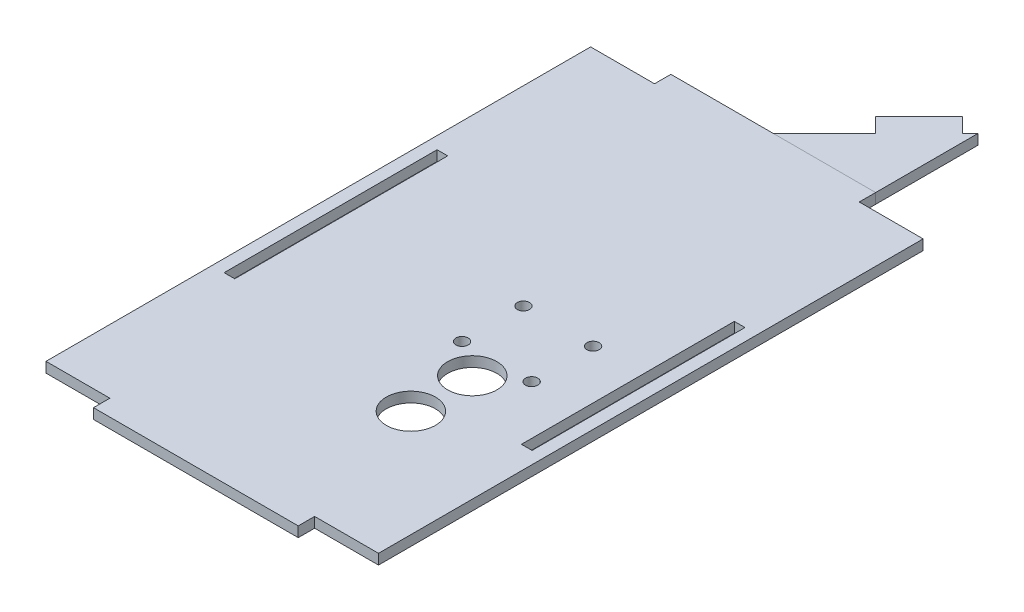
from build123d import *

# Parameters (mm, degrees)
SKETCH1_W           = 2.6
SKETCH1_H           = 52
BOSS_EXTRUDE1_DEPTH = 2.5
SKETCH2_R           = 6
CUT_EXTRUDE1_DEPTH  = 3.5
SKETCH3_R           = 1.5
CUT_EXTRUDE2_DEPTH  = 3.5
SKETCH4_R           = 6
SKETCH4_R_2         = 1.5
CUT_EXTRUDE3_DEPTH  = 3.5
BOSS_EXTRUDE2_DEPTH = 2.5


with BuildPart() as part:
    # Sketch1 → Boss-Extrude1 (new body)
    with BuildSketch(Plane(origin=(0, 0, 0), x_dir=(1, 0, 0), z_dir=(0, 1, 0))):
        Polygon((-25, 66.5), (-40.6, 66.5), (-40.6, -66.5), (-25, -66.5), (-25, -70.5), (25, -70.5), (25, -66.5), (40.6, -66.5), (40.6, 66.5), (25, 66.5), (25, 70.5), (-25, 70.5), align=None)
        with Locations((-36.3, 0)):
            Rectangle(SKETCH1_W, SKETCH1_H, mode=Mode.SUBTRACT)
        with Locations((36.3, 0)):
            Rectangle(SKETCH1_W, SKETCH1_H, mode=Mode.SUBTRACT)
    extrude(amount=BOSS_EXTRUDE1_DEPTH)

    # Sketch2 → Cut-Extrude1 (cut, through all)
    with BuildSketch(Plane.XZ):
        with Locations((14.5, 32.5)):
            Circle(SKETCH2_R)
    extrude(amount=-CUT_EXTRUDE1_DEPTH, mode=Mode.SUBTRACT)

    # Sketch3 → Cut-Extrude2 (cut, through all)
    with BuildSketch(Plane.XZ):
        with Locations((6, 11.5)):
            Circle(SKETCH3_R)
        with Locations((23, 11.5)):
            Circle(SKETCH3_R)
    extrude(amount=-CUT_EXTRUDE2_DEPTH, mode=Mode.SUBTRACT)

    # Sketch4 → Cut-Extrude3 (cut, through all)
    with BuildSketch(Plane(origin=(0, 2.5, 0), x_dir=(1, 0, 0), z_dir=(0, 1, 0))):
        with Locations((14.5, -17.5)):
            Circle(SKETCH4_R)
        with Locations((6, 3.5)):
            Circle(SKETCH4_R_2)
        with Locations((23, 3.5)):
            Circle(SKETCH4_R_2)
    extrude(amount=-CUT_EXTRUDE3_DEPTH, mode=Mode.SUBTRACT)


with BuildPart() as body_2:
    # Sketch5 → Boss-Extrude2 (new body)
    with BuildSketch(Plane(origin=(0, 2.5, 0), x_dir=(1, 0, 0), z_dir=(0, 1, 0))):
        Polygon((12.5, 83), (0, 70.5), (25, 70.5), (25, 95.5), (23.106601718, 93.606601718), (19.571067812, 97.142135624), (8.964466094, 86.535533906), align=None)
    extrude(amount=-BOSS_EXTRUDE2_DEPTH)


solid = Compound([part.part, body_2.part])
